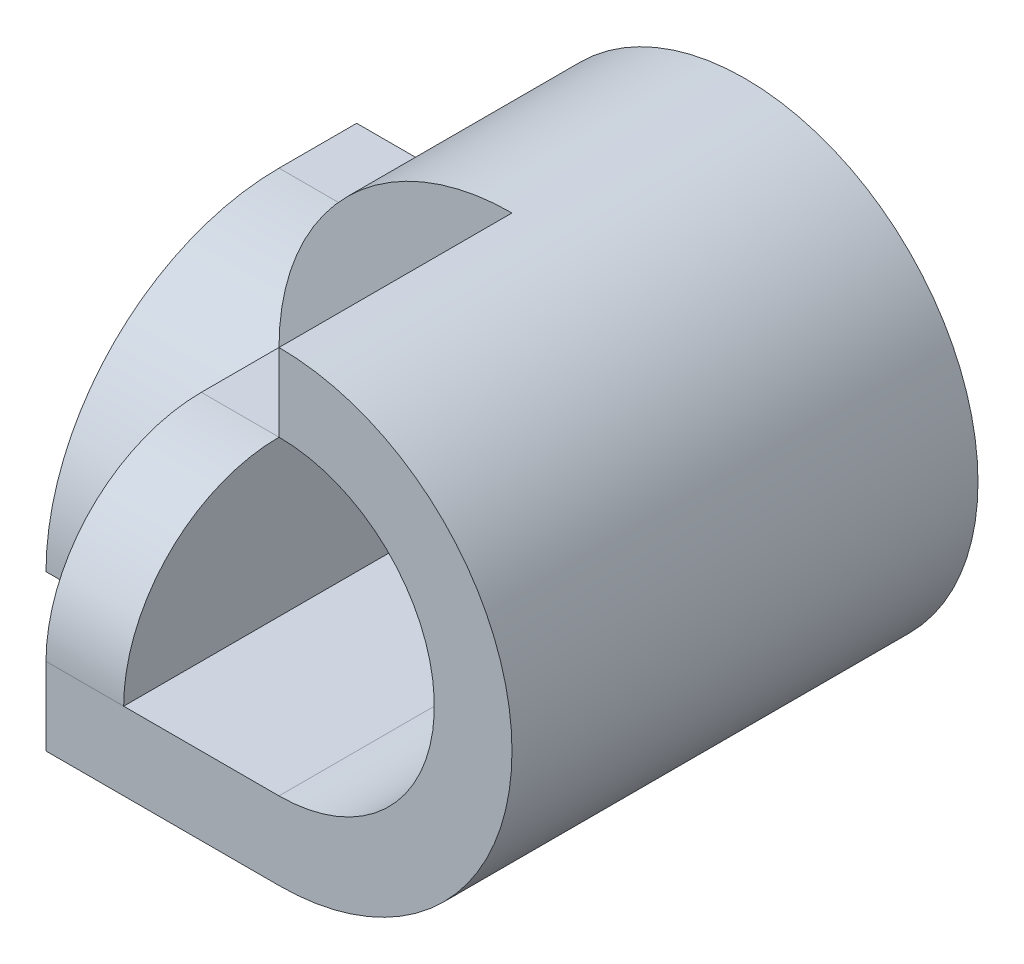
from build123d import *

# Parameters (mm, degrees)
BOSS_EXTRUDE1_DEPTH = 6
BOSS_EXTRUDE2_DEPTH = 2
CUT_EXTRUDE1_DEPTH  = 3


with BuildPart() as part:
    # Sketch2 → Boss-Extrude1 (new body)
    with BuildSketch(Plane.XY):
        with BuildLine():
            ThreePointArc((-1, 2), (4.121320344, 4.121320344), (2, -1))
            Line((2, -1), (-1, -1))
            Line((-1, -1), (-1, 2))
        make_face()
        with BuildLine():
            Line((0, 0), (0, 2))
            ThreePointArc((0, 2), (3.414213562, 3.414213562), (2, 0))
            Line((2, 0), (0, 0))
        make_face(mode=Mode.SUBTRACT)
    extrude(amount=BOSS_EXTRUDE1_DEPTH)

    # Sketch3 → Boss-Extrude2 (add)
    with BuildSketch(Plane.ZY.offset(1)):
        with BuildLine():
            Line((0, 2), (0, -1))
            Line((0, -1), (4, -1))
            ThreePointArc((4, -1), (3.121320344, 1.121320344), (1, 2))
            Line((1, 2), (0, 2))
        make_face()
    extrude(amount=BOSS_EXTRUDE2_DEPTH)

    # Sketch4 → Cut-Extrude1 (cut)
    with BuildSketch(Plane.ZY.offset(1)):
        with BuildLine():
            Line((3, 2), (4, 2))
            ThreePointArc((4, 2), (5.414213562, 1.414213562), (6, 0))
            Line((6, 0), (6, 5))
            Line((6, 5), (3, 5))
            Line((3, 5), (3, 2))
        make_face()
    extrude(amount=-CUT_EXTRUDE1_DEPTH, mode=Mode.SUBTRACT)


solid = part.part
